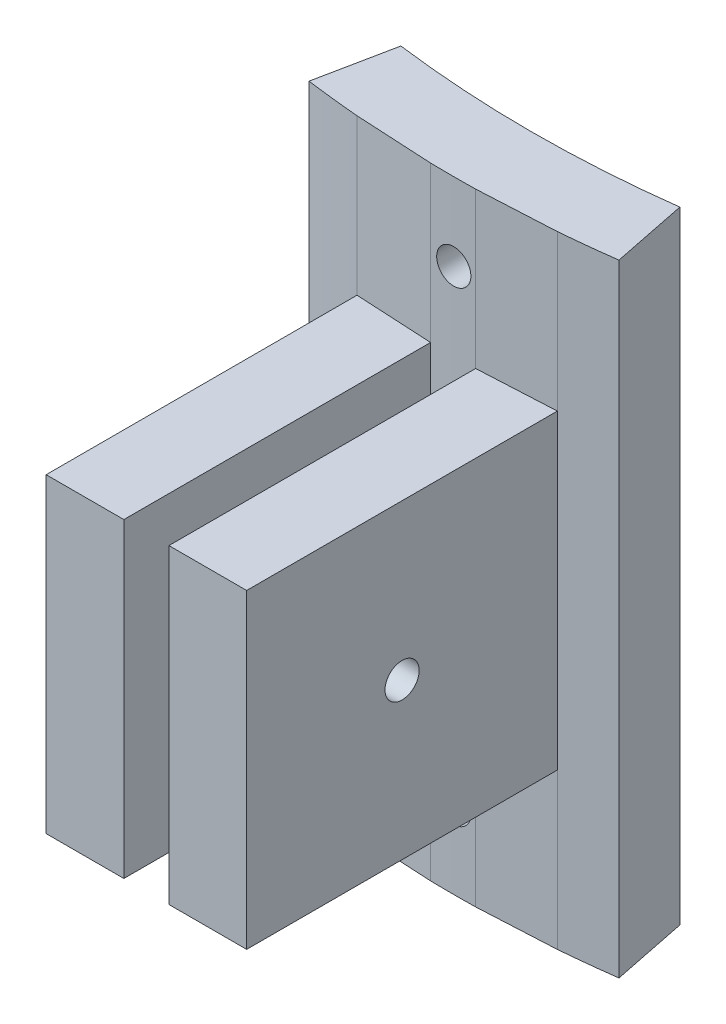
from build123d import *

# Parameters (mm, degrees)
BOSS_EXTRUDE1_DEPTH      = 25.4
SKETCH3_R                = 1.397
CUT_EXTRUDE2_DEPTH       = 25.4
BOSS_EXTRUDE2_DEPTH      = 12.7
BOSS_EXTRUDE2_DEPTH_BACK = 38.1
CUT_EXTRUDE3_REACH       = 34.125
SKETCH5_R                = 1.397


with BuildPart() as part:
    # Sketch1 → Boss-Extrude1 (new body)
    with BuildSketch(Plane(origin=(0, 0, 0), x_dir=(1, 0, 0), z_dir=(0, 1, 0))):
        with BuildLine():
            Line((-8.255, -94.891609086), (-8.255, -120.291609086))
            Line((-8.255, -120.291609086), (-1.905, -120.291609086))
            Line((-1.905, -120.291609086), (-1.905, -95.230948095))
            ThreePointArc((-1.905, -95.230948095), (-0.063511871, -95.249978825), (1.778, -95.233403888))
            Line((1.778, -95.233403888), (1.778, -120.291609086))
            Line((1.778, -120.291609086), (8.128, -120.291609086))
            Line((8.128, -120.291609086), (8.128, -94.902571704))
            ThreePointArc((8.128, -94.902571704), (10.398183486, -94.680728135), (12.662403805, -94.404586911))
            Line((12.662403805, -94.404586911), (11.398535202, -88.166225933))
            ThreePointArc((11.398535202, -88.166225933), (0, -88.9), (-11.398535202, -88.166225933))
            Line((-11.398535202, -88.166225933), (-12.662403805, -94.404586911))
            ThreePointArc((-12.662403805, -94.404586911), (-10.461536366, -94.673749038), (-8.255, -94.891609086))
        make_face()
    extrude(amount=BOSS_EXTRUDE1_DEPTH)

    # Sketch3 → Cut-Extrude2 (cut)
    with BuildSketch(Plane.ZY.offset(8.255)):
        with Locations((107.591609086, 12.7)):
            Circle(SKETCH3_R)
    extrude(amount=-CUT_EXTRUDE2_DEPTH, mode=Mode.SUBTRACT)

    # Sketch4 → Boss-Extrude2 (add, two sides)
    with BuildSketch(Plane(origin=(0, 25.4, 0), x_dir=(1, 0, 0), z_dir=(0, 1, 0))) as boss_extrude2_sk:
        with BuildLine():
            Line((1.778, -95.233403888), (8.128, -94.902571704))
            ThreePointArc((8.128, -94.902571704), (10.398183486, -94.680728135), (12.662403805, -94.404586911))
            Line((12.662403805, -94.404586911), (11.398535202, -88.166225933))
            ThreePointArc((11.398535202, -88.166225933), (0, -88.9), (-11.398535202, -88.166225933))
            Line((-11.398535202, -88.166225933), (-12.662403805, -94.404586911))
            ThreePointArc((-12.662403805, -94.404586911), (-10.461536366, -94.673749038), (-8.255, -94.891609086))
            Line((-8.255, -94.891609086), (-1.905, -95.230948095))
            ThreePointArc((-1.905, -95.230948095), (-0.063511871, -95.249978825), (1.778, -95.233403888))
        make_face()
    extrude(amount=BOSS_EXTRUDE2_DEPTH)
    extrude(boss_extrude2_sk.sketch, amount=-BOSS_EXTRUDE2_DEPTH_BACK)

    # Sketch5 → Cut-Extrude3 (cut, up to next)
    with BuildSketch(Plane.XY.offset(120.291609086), mode=Mode.PRIVATE) as cut_extrude3_sk1:
        with Locations((0, 31.75)):
            Circle(SKETCH5_R)
    cut_extrude3_tool1 = extrude(cut_extrude3_sk1.sketch, amount=-CUT_EXTRUDE3_REACH, mode=Mode.PRIVATE) & part.part
    add(cut_extrude3_tool1.solids().sort_by_distance((0, 31.75, 120.291609))[0], mode=Mode.SUBTRACT)
    # Sketch5 → Cut-Extrude3 (cut, up to next)
    with BuildSketch(Plane.XY.offset(120.291609086), mode=Mode.PRIVATE) as cut_extrude3_sk2:
        with Locations((0, -6.35)):
            Circle(SKETCH5_R)
    cut_extrude3_tool2 = extrude(cut_extrude3_sk2.sketch, amount=-CUT_EXTRUDE3_REACH, mode=Mode.PRIVATE) & part.part
    add(cut_extrude3_tool2.solids().sort_by_distance((0, -6.35, 120.291609))[0], mode=Mode.SUBTRACT)


solid = part.part
